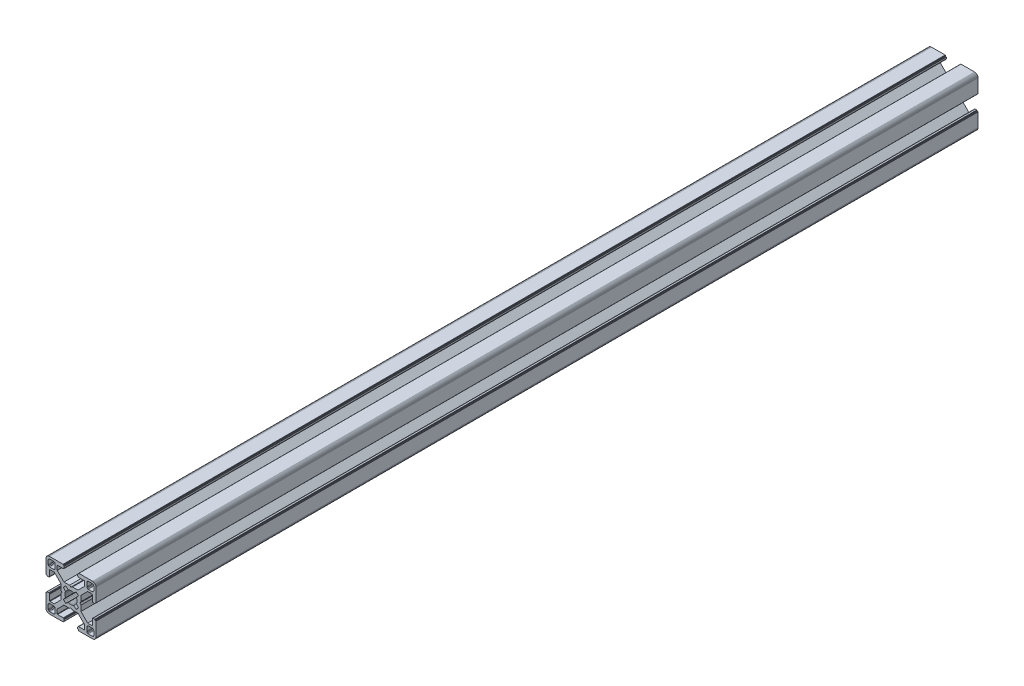
from build123d import *

# Parameters (mm, degrees)
BOSS_EXTRUDE1_DEPTH = 530


with BuildPart() as part:
    # Sketch1 → Boss-Extrude1 (new body)
    with BuildSketch(Plane.XY):
        Polygon((28.34729664, 29.969613999), (28.000000864, 29.999999329), (19.750000909, 29.999999329), (19.715268165, 29.996961355), (19.681595266, 29.987938702), (19.649999216, 29.973205179), (19.621443003, 29.953207821), (19.596790895, 29.928557575), (19.576793537, 29.899999499), (19.562061876, 29.868405312), (19.55303736, 29.834728688), (19.549999386, 29.799999669), (19.549999386, 29.699999839), (19.546961412, 29.665268958), (19.537936896, 29.631596059), (19.523203373, 29.599998146), (19.503207877, 29.571441934), (19.478557631, 29.546789825), (19.449999556, 29.526794329), (19.418403506, 29.512060806), (19.384728745, 29.503038153), (19.349999726, 29.500000179), (19.249999896, 29.500000179), (19.215267517, 29.496958527), (19.181592755, 29.487935874), (19.149996706, 29.47320235), (19.12143863, 29.453206855), (19.096788384, 29.428554746), (19.076791026, 29.399996671), (19.062057503, 29.368402484), (19.05303485, 29.334725859), (19.049996876, 29.299998703), (19.049996876, 28.39999837), (19.059110798, 28.29580945), (19.08618062, 28.194785165), (19.13038119, 28.099997016), (19.190369539, 28.014324653), (19.264324002, 27.94037019), (19.349996366, 27.88038184), (19.444784515, 27.836181271), (19.545806937, 27.809111449), (19.650010894, 27.799984574), (23.050010706, 27.799984574), (23.084741588, 27.7969466), (23.118414487, 27.787923946), (23.150012399, 27.773190423), (23.178568612, 27.753193065), (23.203220721, 27.728542819), (23.223218079, 27.699984744), (23.237949739, 27.668386831), (23.246974255, 27.634713932), (23.25001142, 27.59998608), (23.25001142, 25.049987618), (19.204474482, 20.999982084), (15.900007876, 20.999982084), (15.000008474, 20.48483404), (14.10000814, 20.999982084), (10.795543398, 20.999982084), (7.997342887, 23.801274731), (6.750011387, 25.049984589), (6.750011387, 27.599983051), (6.753049362, 27.634713932), (6.762072946, 27.668386831), (6.776805538, 27.699984744), (6.796801965, 27.728542819), (6.821454073, 27.753193065), (6.850011218, 27.773190423), (6.881607267, 27.787923946), (6.915282029, 27.7969466), (6.950011048, 27.799984574), (10.350011791, 27.799984574), (10.45420071, 27.809098497), (10.555223133, 27.836168318), (10.650011282, 27.880368888), (10.735683645, 27.940357238), (10.809638108, 28.014311701), (10.869626458, 28.099984064), (10.913827027, 28.194772213), (10.940895918, 28.295796498), (10.950010772, 28.399985417), (10.950010772, 29.299985751), (10.946974575, 29.334739239), (10.93795065, 29.368415522), (10.923215933, 29.400009153), (10.903218427, 29.428566473), (10.878566319, 29.45321765), (10.849999264, 29.473204166), (10.818403214, 29.487937689), (10.784728453, 29.496960342), (10.749999434, 29.500000179), (10.649999604, 29.500000179), (10.615270585, 29.503038153), (10.581595823, 29.512060806), (10.549999774, 29.526794329), (10.521441698, 29.546789825), (10.496791452, 29.571441934), (10.476795025, 29.599998146), (10.462061502, 29.631596059), (10.453037918, 29.665268958), (10.449999943, 29.699999839), (10.449999943, 29.799999669), (10.446961969, 29.834728688), (10.437938385, 29.868405312), (10.423205793, 29.899999499), (10.403208435, 29.928557575), (10.378557257, 29.953207821), (10.350000113, 29.973205179), (10.318404064, 29.987938702), (10.284729302, 29.996961355), (10.250000283, 29.999999329), (1.999999397, 29.999999329), (1.652702689, 29.969613999), (1.315958682, 29.879383743), (0.999999233, 29.732050374), (0.714424066, 29.532089829), (0.467910431, 29.285576195), (0.267948955, 28.999999166), (0.120614655, 28.684040532), (0.030384399, 28.34729664), (0, 28.000000864), (0, 19.750000909), (0.003037974, 19.715268165), (0.012061559, 19.681595266), (0.026795082, 19.649999216), (0.046790577, 19.621441141), (0.071442686, 19.596789032), (0.09999983, 19.576793537), (0.13159588, 19.562060013), (0.165270641, 19.55303736), (0.19999966, 19.549999386), (0.299999461, 19.549999386), (0.334728509, 19.546959549), (0.368403242, 19.537936896), (0.399999321, 19.523203373), (0.428556465, 19.503207877), (0.453208573, 19.478555769), (0.473204069, 19.449997693), (0.487937592, 19.418403506), (0.496961176, 19.384728745), (0.499999151, 19.349999726), (0.499999151, 19.249998033), (0.503038056, 19.215269014), (0.512060709, 19.181594253), (0.526794232, 19.150000066), (0.546790194, 19.121441524), (0.571441837, 19.096789882), (0.60000029, 19.076794925), (0.631595686, 19.062061999), (0.665270619, 19.053039982), (0.700000626, 19.050000801), (1.60000096, 19.050000801), (1.704189879, 19.059116587), (1.805213233, 19.086186409), (1.90000045, 19.130385115), (1.985673745, 19.190375328), (2.059627277, 19.264327928), (2.119616325, 19.350002154), (2.163816196, 19.444788441), (2.190886018, 19.545812726), (2.200000872, 19.650001645), (2.200000872, 23.050001457), (2.203039777, 23.084732338), (2.212062431, 23.118405237), (2.226795954, 23.15000315), (2.246792381, 23.178559362), (2.271443558, 23.203211471), (2.300000702, 23.223206967), (2.331596752, 23.23794049), (2.365271513, 23.246965006), (2.400001464, 23.250001117), (4.950000857, 23.250001117), (7.997332093, 20.202670812), (8.995535423, 19.204467788), (8.995535423, 15.900001182), (9.515148227, 15.00000178), (8.995535423, 14.100002378), (8.995535423, 10.795536704), (4.950000857, 6.750002138), (2.400001464, 6.750002138), (2.365271513, 6.753040112), (2.331596752, 6.762063697), (2.300000702, 6.77679722), (2.271443558, 6.796793647), (2.246792381, 6.821444824), (2.226795954, 6.850001968), (2.212062431, 6.881598018), (2.203039777, 6.915272779), (2.200000872, 6.950002729), (2.200000872, 10.350002542), (2.190896812, 10.454174265), (2.16382699, 10.555197618), (2.119627119, 10.649984836), (2.059638071, 10.735658131), (1.985684539, 10.809611663), (1.900011244, 10.869600944), (1.805224027, 10.913800582), (1.704200673, 10.940870404), (1.600011754, 10.949986189), (0.70001142, 10.949986189), (0.665281355, 10.946948596), (0.631606253, 10.937926283), (0.600010578, 10.923193954), (0.571451747, 10.903199537), (0.546799638, 10.87854836), (0.526794232, 10.850000195), (0.512060709, 10.818404146), (0.503038056, 10.784730315), (0.499999151, 10.750000365), (0.499999151, 10.650000535), (0.496961176, 10.615270585), (0.487937592, 10.581596754), (0.473204069, 10.550000705), (0.453208573, 10.521443561), (0.428556465, 10.496791452), (0.399999321, 10.476795956), (0.368403242, 10.462062433), (0.334728509, 10.453038849), (0.299999461, 10.449999943), (0.19999966, 10.449999943), (0.165270641, 10.446961969), (0.13159588, 10.437939316), (0.09999983, 10.423205793), (0.071442686, 10.403209366), (0.046790577, 10.378558189), (0.026795082, 10.350000113), (0.012061559, 10.318404064), (0.003037974, 10.284729302), (0, 10.250000283), (0, 1.999999397), (0.030384399, 1.652702689), (0.120614655, 1.315958682), (0.267948955, 0.999999233), (0.467910431, 0.714424066), (0.714424066, 0.467910431), (0.999999233, 0.267948955), (1.315958682, 0.120614655), (1.652702689, 0.030384399), (1.999999397, 0), (10.250000283, 0), (10.284729302, 0.003037974), (10.318404064, 0.012061559), (10.350000113, 0.026795082), (10.378557257, 0.046790577), (10.403208435, 0.071442686), (10.423205793, 0.09999983), (10.437938385, 0.13159588), (10.446961969, 0.165270641), (10.449999943, 0.19999966), (10.449999943, 0.300000422), (10.453037918, 0.334729441), (10.462061502, 0.368404202), (10.476795025, 0.400000252), (10.496791452, 0.428557396), (10.521441698, 0.453208573), (10.549999774, 0.473205), (10.581595823, 0.487938523), (10.615270585, 0.496961176), (10.649999604, 0.500000082), (10.749999434, 0.500000082), (10.784728453, 0.503038056), (10.818403214, 0.512060709), (10.849999264, 0.526794232), (10.878547894, 0.546800104), (10.903198606, 0.571451747), (10.923194493, 0.6000102), (10.93792742, 0.631606528), (10.946949437, 0.66528146), (10.950010772, 0.699984975), (10.950010772, 1.599985308), (10.940895918, 1.704174228), (10.913827027, 1.805197581), (10.869626458, 1.89998573), (10.809638108, 1.985658094), (10.735683645, 2.059612557), (10.650011282, 2.119600674), (10.555223133, 2.163801476), (10.45420071, 2.190870367), (10.350011791, 2.199985221), (6.950011048, 2.199985221), (6.915282029, 2.203024126), (6.881607267, 2.212046779), (6.850011218, 2.226780302), (6.821454073, 2.246776729), (6.796801965, 2.271427907), (6.776805538, 2.299985982), (6.762072946, 2.331582032), (6.753049362, 2.365256793), (6.750011387, 2.399985812), (6.750011387, 4.949985206), (9.787457566, 7.990785077), (10.795545277, 8.999985833), (14.100010019, 8.999985833), (15.000010353, 9.515133877), (15.900009756, 8.999985833), (19.204476361, 8.999985833), (20.21256413, 7.990786065), (23.25001142, 4.949988235), (23.25001142, 2.399988841), (23.246974255, 2.365256793), (23.237949739, 2.331582032), (23.223218079, 2.299985982), (23.203220721, 2.271427907), (23.178568612, 2.246776729), (23.150012399, 2.226780302), (23.118414487, 2.212046779), (23.084741588, 2.203024126), (23.050010706, 2.199985221), (19.650010894, 2.199985221), (19.545806937, 2.190883319), (19.444784515, 2.163814428), (19.349996366, 2.119613626), (19.264324002, 2.059625509), (19.190369539, 1.985671046), (19.13038119, 1.899998682), (19.08618062, 1.805210533), (19.059110798, 1.70418718), (19.049996876, 1.599998261), (19.049996876, 0.699997927), (19.053035506, 0.665268966), (19.062058795, 0.631594374), (19.076792915, 0.599998603), (19.096790813, 0.571440905), (19.121441524, 0.546790194), (19.149999978, 0.526794306), (19.181596306, 0.51206138), (19.215271238, 0.503039363), (19.249999896, 0.500000082), (19.349999726, 0.500000082), (19.384728745, 0.496961176), (19.418403506, 0.487938523), (19.449999556, 0.473205), (19.478557631, 0.453208573), (19.503207877, 0.428557396), (19.523203373, 0.400000252), (19.537936896, 0.368404202), (19.546961412, 0.334729441), (19.549999386, 0.300000422), (19.549999386, 0.19999966), (19.55303736, 0.165270641), (19.562061876, 0.13159588), (19.576793537, 0.09999983), (19.596789964, 0.071441755), (19.621442072, 0.046789646), (19.649998285, 0.02679415), (19.681594335, 0.012060627), (19.715267234, 0.003037043), (19.750000909, 0), (28.000000864, 0), (28.34729664, 0.030384399), (28.684040532, 0.120614655), (28.999999166, 0.267948955), (29.285576195, 0.467910431), (29.532089829, 0.714424066), (29.732050374, 0.999999233), (29.879383743, 1.315958682), (29.969613999, 1.652702689), (29.999999329, 1.999999397), (29.999999329, 10.250000283), (29.996974806, 10.284715361), (29.987951516, 10.318389952), (29.973217396, 10.349985723), (29.953219499, 10.378543421), (29.928568787, 10.403194133), (29.899999499, 10.423205793), (29.868405312, 10.437939316), (29.834728688, 10.446961969), (29.799999669, 10.449999943), (29.699999839, 10.449999943), (29.664909937, 10.453400043), (29.631233313, 10.462423628), (29.599637263, 10.477157151), (29.57108105, 10.497152646), (29.546427079, 10.521804755), (29.526433446, 10.550361899), (29.511699923, 10.581957949), (29.502675407, 10.615631779), (29.499637433, 10.650361729), (29.499637433, 10.750361559), (29.49697202, 10.784715548), (29.487949367, 10.818389378), (29.473215844, 10.849985428), (29.453220348, 10.878542572), (29.428568239, 10.90319468), (29.400010164, 10.923190176), (29.368415977, 10.937923699), (29.334741215, 10.946947284), (29.300012197, 10.949986189), (28.400011863, 10.949986189), (28.29581215, 10.9408876), (28.194787865, 10.913817778), (28.099999716, 10.86961814), (28.014327352, 10.809628859), (27.940374752, 10.735675327), (27.880384539, 10.650002032), (27.836185833, 10.555214814), (27.809114148, 10.454191461), (27.800000225, 10.350002542), (27.800000225, 6.950002729), (27.796962251, 6.915272779), (27.787939598, 6.881598018), (27.773206075, 6.850001968), (27.753208716, 6.821444824), (27.728558471, 6.796793647), (27.700000395, 6.77679722), (27.668404345, 6.762063697), (27.634729584, 6.753040112), (27.599998702, 6.750002138), (25.05000024, 6.750002138), (23.809199132, 7.99080223), (21.004464477, 10.795534588), (21.004464477, 14.100000262), (20.484851673, 14.999999665), (21.004464477, 15.899999067), (21.004464477, 19.204465672), (25.05000024, 23.250001117), (27.599998702, 23.250001117), (27.634729584, 23.246965006), (27.668404345, 23.23794049), (27.700000395, 23.223206967), (27.728558471, 23.203211471), (27.753208716, 23.178559362), (27.773206075, 23.15000315), (27.787939598, 23.118405237), (27.796962251, 23.084732338), (27.800000225, 23.050001457), (27.800000225, 19.650001645), (27.809114148, 19.545812726), (27.836185833, 19.444788441), (27.880384539, 19.350002154), (27.940370508, 19.264323684), (28.014323108, 19.190371084), (28.099995472, 19.130380872), (28.194783621, 19.086182165), (28.295807906, 19.059112343), (28.400001069, 19.050000801), (29.300001402, 19.050000801), (29.334730421, 19.053040638), (29.368405183, 19.062063291), (29.39999937, 19.076796814), (29.42819671, 19.097149726), (29.452848353, 19.1218023), (29.472843309, 19.150360754), (29.487576235, 19.181955219), (29.496598252, 19.215630151), (29.499637433, 19.250359227), (29.499637433, 19.35036092), (29.502675407, 19.385089939), (29.511699923, 19.4187647), (29.526433446, 19.450358887), (29.546427079, 19.478916963), (29.57108105, 19.503569071), (29.599637263, 19.523564567), (29.631233313, 19.53829809), (29.664909937, 19.547320743), (29.699999839, 19.549999386), (29.799999669, 19.549999386), (29.834728688, 19.55303736), (29.868405312, 19.562060013), (29.899999499, 19.576793537), (29.928557575, 19.596789032), (29.953207821, 19.621441141), (29.973205179, 19.649999216), (29.987938702, 19.681595266), (29.996961355, 19.715268165), (29.999999329, 19.750000909), (29.999999329, 28.000000864), (29.969613999, 28.34729664), (29.879383743, 28.684040532), (29.732050374, 28.999999166), (29.532089829, 29.285576195), (29.285576195, 29.532089829), (28.999999166, 29.732050374), (28.684040532, 29.879383743), align=None)
        Polygon((1.299998723, 25.499999523), (1.299998723, 27.699999511), (1.312309876, 27.856435627), (1.348942518, 28.009016067), (1.408992335, 28.153989464), (1.490981318, 28.287785128), (1.592892222, 28.407108039), (1.71221327, 28.50901708), (1.846008119, 28.591006994), (1.9909814, 28.651056811), (2.143563703, 28.687689453), (2.299998887, 28.699999675), (4.499998875, 28.699999675), (4.656434059, 28.687689453), (4.809016362, 28.651056811), (4.953989759, 28.591006994), (5.087784491, 28.50901708), (5.207106471, 28.407108039), (5.309016444, 28.287785128), (5.391005427, 28.153989464), (5.451056175, 28.009016067), (5.487687886, 27.856435627), (5.499999039, 27.699999511), (5.499999039, 25.499999523), (5.487687886, 25.34356527), (5.451056175, 25.190982968), (5.391005427, 25.04600957), (5.309016444, 24.912213907), (5.207106471, 24.792892858), (5.087784491, 24.690981954), (4.953989759, 24.60899204), (4.809016362, 24.548944086), (4.656434059, 24.512309581), (4.499998875, 24.499999359), (2.299998887, 24.499999359), (2.143563703, 24.512309581), (1.9909814, 24.548944086), (1.846008119, 24.60899204), (1.71221327, 24.690981954), (1.592892222, 24.792892858), (1.490981318, 24.912213907), (1.408992335, 25.04600957), (1.348942518, 25.190982968), (1.312309876, 25.34356527), align=None, mode=Mode.SUBTRACT)
        Polygon((25.34356527, 28.687689453), (25.499999523, 28.699999675), (27.699999511, 28.699999675), (27.856435627, 28.687689453), (28.009017929, 28.651056811), (28.153991327, 28.591006994), (28.28778699, 28.50901708), (28.407108039, 28.407108039), (28.50901708, 28.287785128), (28.591006994, 28.153989464), (28.651056811, 28.009016067), (28.687689453, 27.856435627), (28.700001538, 27.699999511), (28.700001538, 25.499999523), (28.687689453, 25.34356527), (28.651056811, 25.190982968), (28.591006994, 25.04600957), (28.50901708, 24.912213907), (28.407108039, 24.792892858), (28.28778699, 24.690981954), (28.153991327, 24.60899204), (28.009017929, 24.548944086), (27.856435627, 24.512309581), (27.699999511, 24.499999359), (25.499999523, 24.499999359), (25.34356527, 24.512309581), (25.190982968, 24.548944086), (25.04600957, 24.60899204), (24.912215769, 24.690981954), (24.792892858, 24.792892858), (24.690981954, 24.912213907), (24.608993903, 25.04600957), (24.548944086, 25.190982968), (24.512311444, 25.34356527), (24.500001222, 25.499999523), (24.500001222, 27.699999511), (24.512311444, 27.856435627), (24.548944086, 28.009016067), (24.608993903, 28.153989464), (24.690981954, 28.287785128), (24.792892858, 28.407108039), (24.912215769, 28.50901708), (25.04600957, 28.591006994), (25.190982968, 28.651056811), align=None, mode=Mode.SUBTRACT)
        Polygon((14.999999665, 18.649999052), (15.550030395, 18.608318642), (16.087498516, 18.484227359), (16.600128263, 18.280562013), (18.13592948, 19.518401474), (18.644984812, 19.11874488), (19.103571773, 18.662061542), (19.505336881, 18.154669553), (18.280562013, 16.600130126), (18.484227359, 16.087498516), (18.608318642, 15.550030395), (18.649999052, 14.999999665), (18.608318642, 14.449968934), (18.484227359, 13.912500814), (18.280562013, 13.399870135), (19.505336881, 11.845329776), (19.103571773, 11.337937787), (18.644984812, 10.881252587), (18.13592948, 10.481598787), (16.600128263, 11.719437316), (16.087498516, 11.515771039), (15.550030395, 11.391680688), (14.999999665, 11.349999346), (14.449968934, 11.391680688), (13.912500814, 11.515771039), (13.399870135, 11.719437316), (11.864069849, 10.481598787), (11.355013587, 10.881252587), (10.896427557, 11.337937787), (10.494662449, 11.845329776), (11.719438247, 13.399870135), (11.515771039, 13.912500814), (11.391680688, 14.449968934), (11.349999346, 14.999999665), (11.391680688, 15.550030395), (11.515771039, 16.087498516), (11.719438247, 16.600130126), (10.494662449, 18.154669553), (10.896427557, 18.662061542), (11.355013587, 19.11874488), (11.864069849, 19.518401474), (13.399870135, 18.280562013), (13.912500814, 18.484227359), (14.449968934, 18.608318642), align=None, mode=Mode.SUBTRACT)
        Polygon((4.499998875, 1.299999771), (2.299998887, 1.299999771), (2.143563703, 1.312310807), (1.9909814, 1.348942518), (1.846008119, 1.408992335), (1.71221327, 1.490982249), (1.592892222, 1.592892222), (1.490981318, 1.712214202), (1.408992335, 1.846008934), (1.348942518, 1.990982331), (1.312309876, 2.143564634), (1.299998723, 2.299998887), (1.299998723, 4.499999806), (1.312309876, 4.656434059), (1.348942518, 4.809017293), (1.408992335, 4.95399069), (1.490981318, 5.087785423), (1.592892222, 5.207106471), (1.71221327, 5.309017375), (1.846008119, 5.391006358), (1.9909814, 5.451056175), (2.143563703, 5.487688817), (2.299998887, 5.49999997), (4.499998875, 5.49999997), (4.656434059, 5.487688817), (4.809016362, 5.451056175), (4.953989759, 5.391006358), (5.087784491, 5.309017375), (5.207106471, 5.207106471), (5.309016444, 5.087785423), (5.391005427, 4.95399069), (5.451056175, 4.809017293), (5.487687886, 4.656434059), (5.499999039, 4.499999806), (5.499999039, 2.299998887), (5.487687886, 2.143564634), (5.451056175, 1.990982331), (5.391005427, 1.846008934), (5.309016444, 1.712214202), (5.207106471, 1.592892222), (5.087784491, 1.490982249), (4.953989759, 1.408992335), (4.809016362, 1.348942518), (4.656434059, 1.312310807), align=None, mode=Mode.SUBTRACT)
        Polygon((27.699999511, 1.299999771), (25.499999523, 1.299999771), (25.34356527, 1.312310807), (25.190982968, 1.348942518), (25.04600957, 1.408992335), (24.912215769, 1.490982249), (24.792892858, 1.592892222), (24.690981954, 1.712214202), (24.608993903, 1.846008934), (24.548944086, 1.990982331), (24.512311444, 2.143564634), (24.500001222, 2.299998887), (24.500001222, 4.499999806), (24.512311444, 4.656434059), (24.548944086, 4.809017293), (24.608993903, 4.95399069), (24.690981954, 5.087785423), (24.792892858, 5.207106471), (24.912215769, 5.309017375), (25.04600957, 5.391006358), (25.190982968, 5.451056175), (25.34356527, 5.487688817), (25.499999523, 5.49999997), (27.699999511, 5.49999997), (27.856435627, 5.487688817), (28.009017929, 5.451056175), (28.153991327, 5.391006358), (28.28778699, 5.309017375), (28.407108039, 5.207106471), (28.50901708, 5.087785423), (28.591006994, 4.95399069), (28.651056811, 4.809017293), (28.687689453, 4.656434059), (28.700001538, 4.499999806), (28.700001538, 2.299998887), (28.687689453, 2.143564634), (28.651056811, 1.990982331), (28.591006994, 1.846008934), (28.50901708, 1.712214202), (28.407108039, 1.592892222), (28.28778699, 1.490982249), (28.153991327, 1.408992335), (28.009017929, 1.348942518), (27.856435627, 1.312310807), align=None, mode=Mode.SUBTRACT)
    extrude(amount=-BOSS_EXTRUDE1_DEPTH)


solid = part.part
